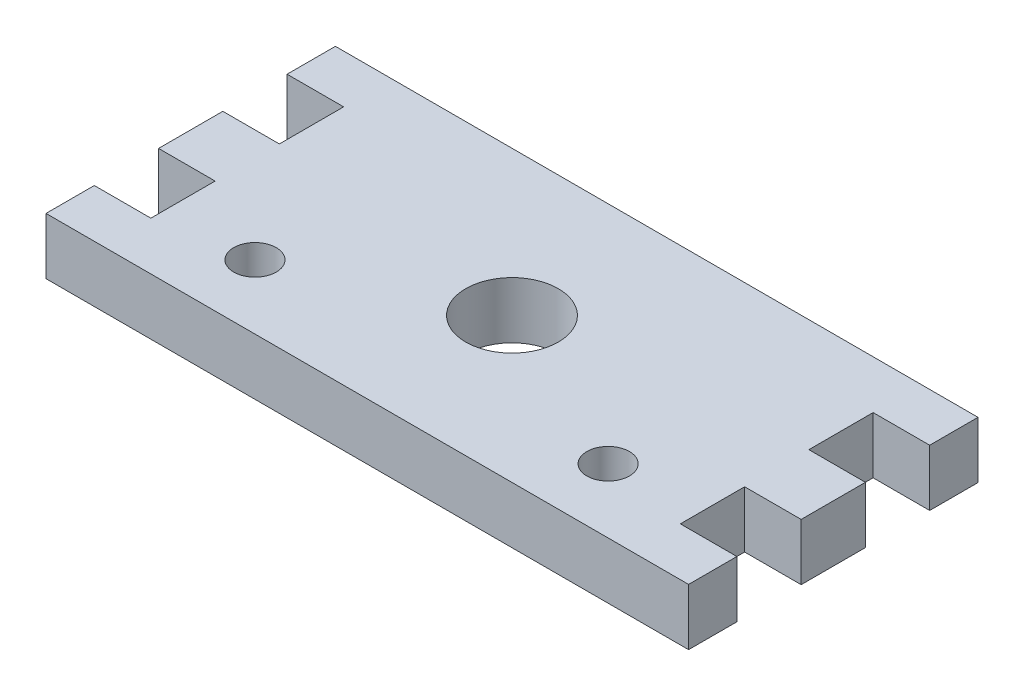
from build123d import *

# Parameters (mm, degrees)
SKETCH1_R           = 4.575
SKETCH1_R_2         = 2.1
BOSS_EXTRUDE1_DEPTH = 5.588


with BuildPart() as part:
    # Sketch1 → Boss-Extrude1 (new body)
    with BuildSketch(Plane(origin=(0, 0, 0), x_dir=(1, 0, 0), z_dir=(0, 1, 0))):
        Polygon((0, 0), (63.5, 0), (63.5, 4.775), (57.912, 4.775), (57.912, 11.125), (63.5, 11.125), (63.5, 17.475), (57.912, 17.475), (57.912, 23.825), (63.5, 23.825), (63.5, 28.6), (0, 28.6), (0, 23.825), (5.588, 23.825), (5.588, 17.475), (0, 17.475), (0, 11.125), (5.588, 11.125), (5.588, 4.775), (0, 4.775), align=None)
        with Locations((31.75, 14.3)):
            Circle(SKETCH1_R, mode=Mode.SUBTRACT)
        with Locations((14.3, 6.35)):
            Circle(SKETCH1_R_2, mode=Mode.SUBTRACT)
        with Locations((49.2, 6.35)):
            Circle(SKETCH1_R_2, mode=Mode.SUBTRACT)
    extrude(amount=BOSS_EXTRUDE1_DEPTH)


solid = part.part
